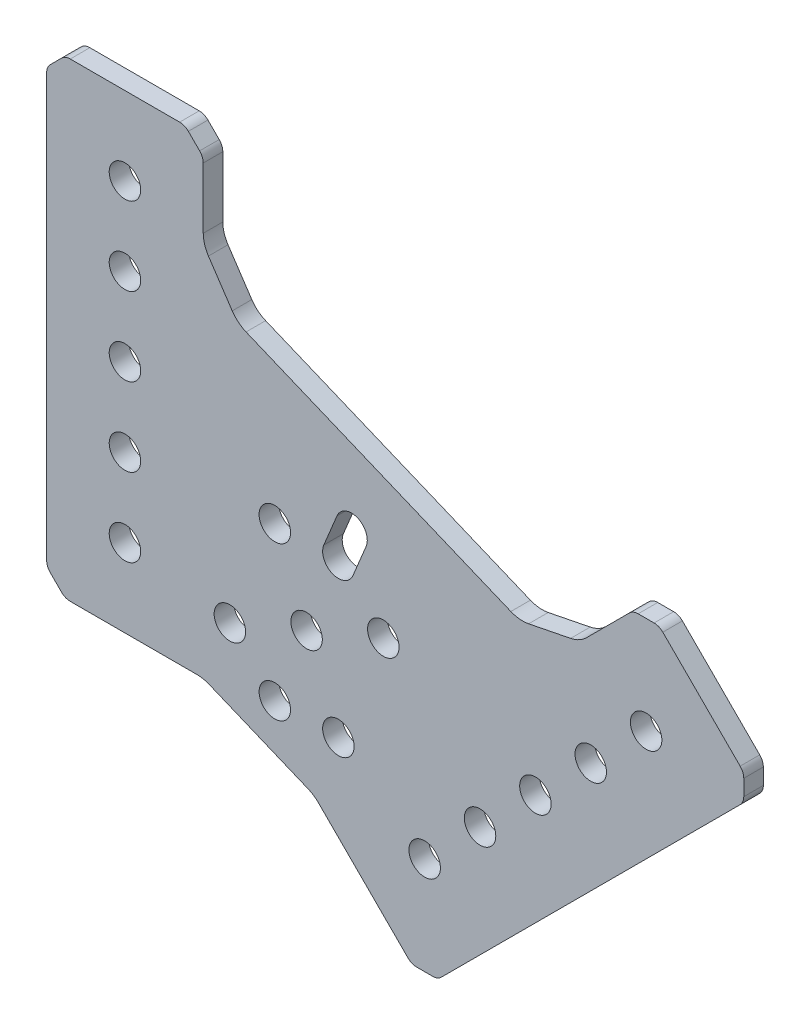
from build123d import *

# Parameters (mm, degrees)
SKETCH1_R           = 2.5527
BOSS_EXTRUDE1_DEPTH = 3.175


with BuildPart() as part:
    # Sketch1 → Boss-Extrude1 (new body)
    with BuildSketch(Plane(origin=(0, 0, 0), x_dir=(-1, 0, 0), z_dir=(0, 0, -1))):
        with BuildLine():
            Line((-2.414213562, 0.585786438), (-0.585786438, 2.414213562))
            ThreePointArc((-0.585786438, 2.414213562), (-0.152240935, 3.06306026), (0, 3.828427125))
            Line((0, 3.828427125), (0, 72.371572875))
            ThreePointArc((0, 72.371572875), (-0.152240935, 73.13693974), (-0.585786438, 73.785786438))
            Line((-0.585786438, 73.785786438), (-2.414213562, 75.614213562))
            ThreePointArc((-2.414213562, 75.614213562), (-3.06306026, 76.047759065), (-3.828427125, 76.2))
            Line((-3.828427125, 76.2), (-21.571572875, 76.2))
            ThreePointArc((-21.571572875, 76.2), (-22.33693974, 76.047759065), (-22.985786438, 75.614213562))
            Line((-22.985786438, 75.614213562), (-24.814213562, 73.785786438))
            ThreePointArc((-24.814213562, 73.785786438), (-25.247759065, 73.13693974), (-25.4, 72.371572875))
            Line((-25.4, 72.371572875), (-25.4, 62.502257193))
            ThreePointArc((-25.4, 62.502257193), (-25.615298321, 61.050833807), (-26.242651938, 59.724406028))
            Line((-26.242651938, 59.724406028), (-30.100625257, 53.950540928))
            ThreePointArc((-30.100625257, 53.950540928), (-31.086006897, 52.863339826), (-32.344556156, 52.10899443))
            Line((-32.344556156, 52.10899443), (-75.296592814, 34.317678315))
            ThreePointArc((-75.296592814, 34.317678315), (-76.719924274, 33.961152344), (-78.185461586, 34.033149576))
            Line((-78.185461586, 34.033149576), (-84.996199847, 35.387889647))
            ThreePointArc((-84.996199847, 35.387889647), (-86.377731921, 35.882209727), (-87.556282143, 36.756282143))
            Line((-87.556282143, 36.756282143), (-94.534942187, 43.734942187))
            ThreePointArc((-94.534942187, 43.734942187), (-95.183788885, 44.16848769), (-95.94915575, 44.320728625))
            Line((-95.94915575, 44.320728625), (-98.534942187, 44.320728625))
            ThreePointArc((-98.534942187, 44.320728625), (-99.300309052, 44.16848769), (-99.94915575, 43.734942187))
            Line((-99.94915575, 43.734942187), (-112.49545443, 31.188643508))
            ThreePointArc((-112.49545443, 31.188643508), (-112.928999932, 30.53979681), (-113.081240867, 29.774429945))
            Line((-113.081240867, 29.774429945), (-113.081240867, 27.188643508))
            ThreePointArc((-113.081240867, 27.188643508), (-112.928999932, 26.423276643), (-112.49545443, 25.774429945))
            Line((-112.49545443, 25.774429945), (-64.028131265, -22.692893219))
            ThreePointArc((-64.028131265, -22.692893219), (-63.379284568, -23.126438721), (-62.613917703, -23.278679656))
            Line((-62.613917703, -23.278679656), (-60.028131265, -23.278679656))
            ThreePointArc((-60.028131265, -23.278679656), (-59.262764401, -23.126438721), (-58.613917703, -22.692893219))
            Line((-58.613917703, -22.692893219), (-44.063773661, -8.142749177))
            ThreePointArc((-44.063773661, -8.142749177), (-43.30609092, -7.520935021), (-42.441656917, -7.05888542))
            Line((-42.441656917, -7.05888542), (-26.318855325, -0.380602337))
            ThreePointArc((-26.318855325, -0.380602337), (-25.380889773, -0.096073598), (-24.405438163, 0))
            Line((-24.405438163, 0), (-3.828427125, 0))
            ThreePointArc((-3.828427125, 0), (-3.06306026, 0.152240935), (-2.414213562, 0.585786438))
        make_face()
        with Locations((-29.720392856, 9.920375508)):
            Circle(SKETCH1_R, mode=Mode.SUBTRACT)
        with Locations((-47.32029795, 2.630256121)):
            Circle(SKETCH1_R, mode=Mode.SUBTRACT)
        with Locations((-12.7, 12.7)):
            Circle(SKETCH1_R, mode=Mode.SUBTRACT)
        with Locations((-12.7, 38.1)):
            Circle(SKETCH1_R, mode=Mode.SUBTRACT)
        with Locations((-12.7, 63.5)):
            Circle(SKETCH1_R, mode=Mode.SUBTRACT)
        with Locations((-12.7, 25.4)):
            Circle(SKETCH1_R, mode=Mode.SUBTRACT)
        with Locations((-12.7, 50.8)):
            Circle(SKETCH1_R, mode=Mode.SUBTRACT)
        with Locations((-70.301280605, 1.540768363)):
            Circle(SKETCH1_R, mode=Mode.SUBTRACT)
        with Locations((-88.261792847, 19.501280605)):
            Circle(SKETCH1_R, mode=Mode.SUBTRACT)
        with Locations((-97.242048969, 28.481536726)):
            Circle(SKETCH1_R, mode=Mode.SUBTRACT)
        with Locations((-79.281536726, 10.521024484)):
            Circle(SKETCH1_R, mode=Mode.SUBTRACT)
        with Locations((-61.321024484, -7.439487758)):
            Circle(SKETCH1_R, mode=Mode.SUBTRACT)
        with Locations((-37.010512242, 27.520280602)):
            Circle(SKETCH1_R, mode=Mode.SUBTRACT)
        with Locations((-54.610417336, 20.230161215)):
            Circle(SKETCH1_R, mode=Mode.SUBTRACT)
        with Locations((-42.165405096, 15.075268362)):
            Circle(SKETCH1_R, mode=Mode.SUBTRACT)
        with Locations((-37.010512242, 2.630256121)):
            Circle(SKETCH1_R, mode=Mode.SUBTRACT)
        with BuildLine():
            Line((-49.678685233, 26.543404604), (-51.813911765, 31.698297458))
            ThreePointArc((-51.813911765, 31.698297458), (-50.43240048, 35.033560738), (-47.0971372, 33.652049454))
            Line((-47.0971372, 33.652049454), (-44.961910667, 28.4971566))
            ThreePointArc((-44.961910667, 28.4971566), (-46.343421952, 25.161893319), (-49.678685233, 26.543404604))
        make_face(mode=Mode.SUBTRACT)
    extrude(amount=-BOSS_EXTRUDE1_DEPTH)


solid = part.part
